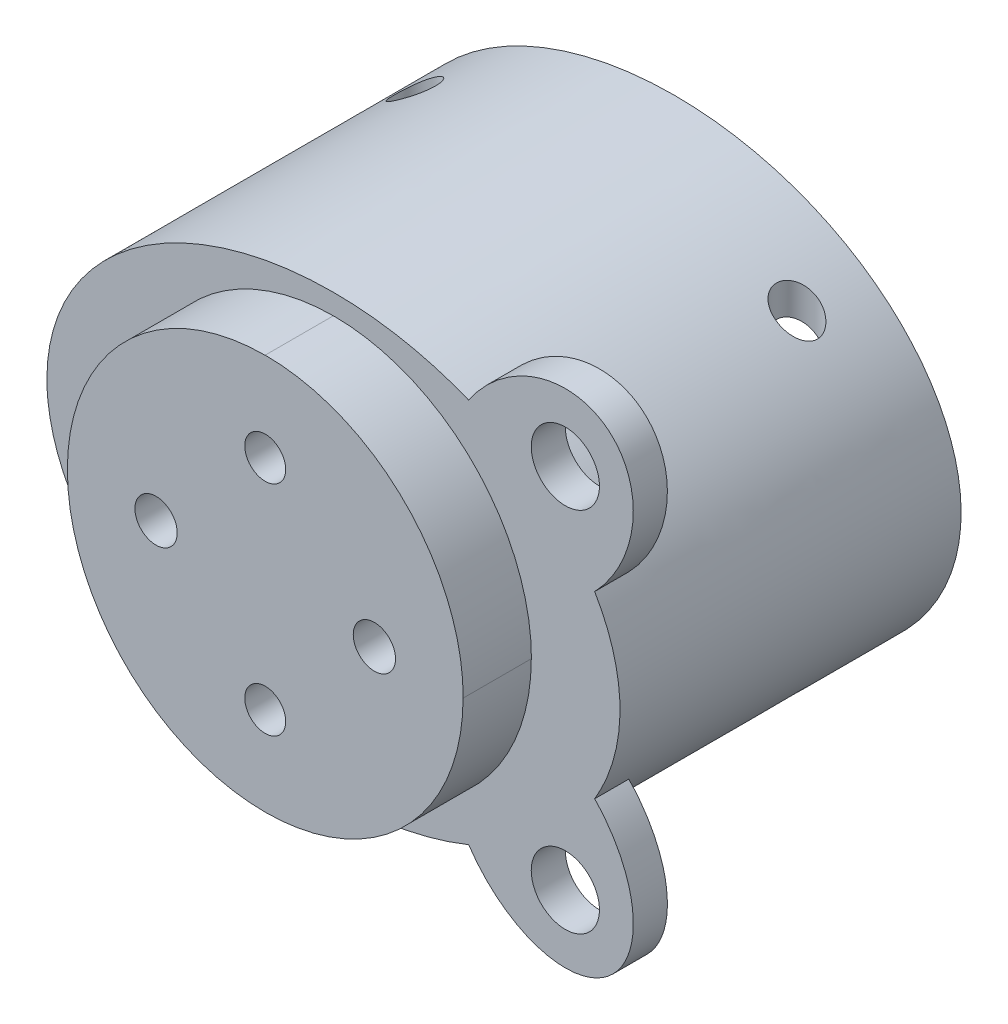
from build123d import *

# Parameters (mm, degrees)
SKETCH_1_R                      = 14.5
EXTRUDE_1_DEPTH                 = 5
EXTRUDE_2_DEPTH                 = 5
SKETCH_10_RX                    = 21
SKETCH_10_RY                    = 16
SKETCH_10_RX_2                  = 19
SKETCH_10_RY_2                  = 14
EXTRUDE_4_DEPTH                 = 25
SKETCH_12_RX                    = 19
SKETCH_12_RY                    = 14
EXTRUDE_5_DEPTH                 = 2
SKETCH_15_R                     = 2.5
EXTRUDE_7_DEPTH                 = 2.5
CUT_EXTRUDE_6_REACH             = 20.388
SKETCH_16_R                     = 1.5
CUT_EXTRUDE_6_DIRECTION_2_REACH = 20.388
CUT_EXTRUDE_7_REACH             = 32
SKETCH_17_R                     = 1.55
SKETCH_17_R_2                   = 1.5
CUT_EXTRUDE_10_DEPTH            = 2.5


with BuildPart() as part:
    # 草图1 → 凸台-拉伸1 (new body)
    with BuildSketch(Plane.XY):
        Circle(SKETCH_1_R)
    extrude(amount=EXTRUDE_1_DEPTH)

    # 草图2 → 凸台-拉伸2 (add)
    with BuildSketch(Plane(origin=(0, 0, 0), x_dir=(-1, 0, 0), z_dir=(0, 0, -1))):
        with BuildLine():
            Line((-14.51, 0), (0, 0))
            Line((0, 0), (0, 14.51))
            ThreePointArc((0, 14.51), (-10.260119395, 10.260119395), (-14.51, 0))
        make_face()
    extrude(amount=-EXTRUDE_2_DEPTH)

    # 草图10 → 凸台-拉伸4 (add)
    with BuildSketch(Plane(origin=(0, 0, 0), x_dir=(-1, 0, 0), z_dir=(0, 0, -1))):
        with Locations((0, 0)):
            Ellipse(SKETCH_10_RX, SKETCH_10_RY)
        with Locations(Location((0, 0), (0, 0, 180))):
            Ellipse(SKETCH_10_RX_2, SKETCH_10_RY_2, mode=Mode.SUBTRACT)
    extrude(amount=EXTRUDE_4_DEPTH)

    # 草图12 → 凸台-拉伸5 (add)
    with BuildSketch(Plane(origin=(0, 0, 0), x_dir=(-1, 0, 0), z_dir=(0, 0, -1))):
        with Locations(Location((0, 0), (0, 0, 0))):
            Ellipse(SKETCH_12_RX, SKETCH_12_RY)
    extrude(amount=EXTRUDE_5_DEPTH)

    # 草图15 → 凸台-拉伸7 (add)
    with BuildSketch(Plane.XY):
        with BuildLine():
            Line((9.868300698, 14.041895092), (19.101285737, 6.53464828))
            add(Edge.make_bspline(
                [(19.101285737, 6.53464828), (25.445309186, 13.018812615), (20.143892045, 17.329341308), (14.842474903, 21.639870001), (9.868300698, 14.041895092)],
                knots=[1.431530137, 1.431530137, 1.431530137, 3.131885125, 3.131885125, 4.832240113, 4.832240113, 4.832240113], degree=2, weights=[1, 0.659849788, 1, 0.659849788, 1]))
        make_face()
        with Locations((16.994596472, 13.445842819)):
            Circle(SKETCH_15_R, mode=Mode.SUBTRACT)
        with BuildLine():
            Line((9.868300698, -14.041895092), (19.101285737, -6.53464828))
            add(Edge.make_bspline(
                [(9.868300698, -14.041895092), (14.842474903, -21.639870001), (20.143892045, -17.329341308), (25.445309186, -13.018812615), (19.101285737, -6.53464828)],
                knots=[4.592537848, 4.592537848, 4.592537848, 6.292892836, 6.292892836, 7.993247824, 7.993247824, 7.993247824], degree=2, weights=[1, 0.659849788, 1, 0.659849788, 1]))
        make_face()
        with Locations((16.994596472, -13.445842819)):
            Circle(SKETCH_15_R, mode=Mode.SUBTRACT)
    extrude(amount=-EXTRUDE_7_DEPTH)

    # 草图16 → 切除-拉伸6 (cut, up to next)
    with BuildSketch(Plane.XZ, mode=Mode.PRIVATE) as cut_extrude_6_sk1:
        with Locations((14, -19.968191924)):
            Circle(SKETCH_16_R)
    cut_extrude_6_tool1 = extrude(cut_extrude_6_sk1.sketch, amount=-CUT_EXTRUDE_6_REACH, mode=Mode.PRIVATE) & part.part
    add(cut_extrude_6_tool1.solids().sort_by_distance((14, 0, -19.968192))[0], mode=Mode.SUBTRACT)
    # 草图16 → 切除-拉伸6 (cut, up to next)
    with BuildSketch(Plane.XZ, mode=Mode.PRIVATE) as cut_extrude_6_sk2:
        with Locations((-14, -19.968191924)):
            Circle(SKETCH_16_R)
    cut_extrude_6_tool2 = extrude(cut_extrude_6_sk2.sketch, amount=-CUT_EXTRUDE_6_REACH, mode=Mode.PRIVATE) & part.part
    add(cut_extrude_6_tool2.solids().sort_by_distance((-14, 0, -19.968192))[0], mode=Mode.SUBTRACT)

    # 草图16 → 切除-拉伸6 direction 2 (cut, up to next)
    with BuildSketch(Plane.XZ, mode=Mode.PRIVATE) as cut_extrude_6_direction_2_sk1:
        with Locations((14, -19.968191924)):
            Circle(SKETCH_16_R)
    cut_extrude_6_direction_2_tool1 = extrude(cut_extrude_6_direction_2_sk1.sketch, amount=CUT_EXTRUDE_6_DIRECTION_2_REACH, mode=Mode.PRIVATE) & part.part
    add(cut_extrude_6_direction_2_tool1.solids().sort_by_distance((14, 0, -19.968192))[0], mode=Mode.SUBTRACT)
    # 草图16 → 切除-拉伸6 direction 2 (cut, up to next)
    with BuildSketch(Plane.XZ, mode=Mode.PRIVATE) as cut_extrude_6_direction_2_sk2:
        with Locations((-14, -19.968191924)):
            Circle(SKETCH_16_R)
    cut_extrude_6_direction_2_tool2 = extrude(cut_extrude_6_direction_2_sk2.sketch, amount=CUT_EXTRUDE_6_DIRECTION_2_REACH, mode=Mode.PRIVATE) & part.part
    add(cut_extrude_6_direction_2_tool2.solids().sort_by_distance((-14, 0, -19.968192))[0], mode=Mode.SUBTRACT)

    # 草图17 → 切除-拉伸7 (cut, up to next)
    with BuildSketch(Plane.XY.offset(5), mode=Mode.PRIVATE) as cut_extrude_7_sk1:
        with Locations((-8, 0)):
            Circle(SKETCH_17_R)
    cut_extrude_7_tool1 = extrude(cut_extrude_7_sk1.sketch, amount=-CUT_EXTRUDE_7_REACH, mode=Mode.PRIVATE) & part.part
    add(cut_extrude_7_tool1.solids().sort_by_distance((-8, 0, 5))[0], mode=Mode.SUBTRACT)
    # 草图17 → 切除-拉伸7 (cut, up to next)
    with BuildSketch(Plane.XY.offset(5), mode=Mode.PRIVATE) as cut_extrude_7_sk2:
        with Locations((8, 0)):
            Circle(SKETCH_17_R)
    cut_extrude_7_tool2 = extrude(cut_extrude_7_sk2.sketch, amount=-CUT_EXTRUDE_7_REACH, mode=Mode.PRIVATE) & part.part
    add(cut_extrude_7_tool2.solids().sort_by_distance((8, 0, 5))[0], mode=Mode.SUBTRACT)
    # 草图17 → 切除-拉伸7 (cut, up to next)
    with BuildSketch(Plane.XY.offset(5), mode=Mode.PRIVATE) as cut_extrude_7_sk3:
        with Locations((0, 8)):
            Circle(SKETCH_17_R_2)
    cut_extrude_7_tool3 = extrude(cut_extrude_7_sk3.sketch, amount=-CUT_EXTRUDE_7_REACH, mode=Mode.PRIVATE) & part.part
    add(cut_extrude_7_tool3.solids().sort_by_distance((0, 8, 5))[0], mode=Mode.SUBTRACT)
    # 草图17 → 切除-拉伸7 (cut, up to next)
    with BuildSketch(Plane.XY.offset(5), mode=Mode.PRIVATE) as cut_extrude_7_sk4:
        with Locations((0, -8)):
            Circle(SKETCH_17_R_2)
    cut_extrude_7_tool4 = extrude(cut_extrude_7_sk4.sketch, amount=-CUT_EXTRUDE_7_REACH, mode=Mode.PRIVATE) & part.part
    add(cut_extrude_7_tool4.solids().sort_by_distance((0, -8, 5))[0], mode=Mode.SUBTRACT)

    # 草图19 → 切除-拉伸10 (cut)
    with BuildSketch(Plane(origin=(0, 0, -2), x_dir=(-1, 0, 0), z_dir=(0, 0, -1))):
        Polygon((-5.423112866, -1.544944302), (-5.37359542, 1.45917757), (-7.950482554, 3.004121872), (-10.576887134, 1.544944302), (-10.62640458, -1.45917757), (-8.049517446, -3.004121872), align=None)
        Polygon((5.458391585, -1.717708514), (8.216775002, -3.059951711), (10.758383417, -1.342243197), (10.541608415, 1.717708514), (7.783224998, 3.059951711), (5.241616583, 1.342243197), align=None)
        Polygon((0, 4.88), (2.70199926, 6.44), (2.70199926, 9.56), (0, 11.12), (-2.70199926, 9.56), (-2.70199926, 6.44), align=None)
        Polygon((0, -11.12), (2.70199926, -9.56), (2.70199926, -6.44), (0, -4.88), (-2.70199926, -6.44), (-2.70199926, -9.56), align=None)
    extrude(amount=-CUT_EXTRUDE_10_DEPTH, mode=Mode.SUBTRACT)


solid = part.part
